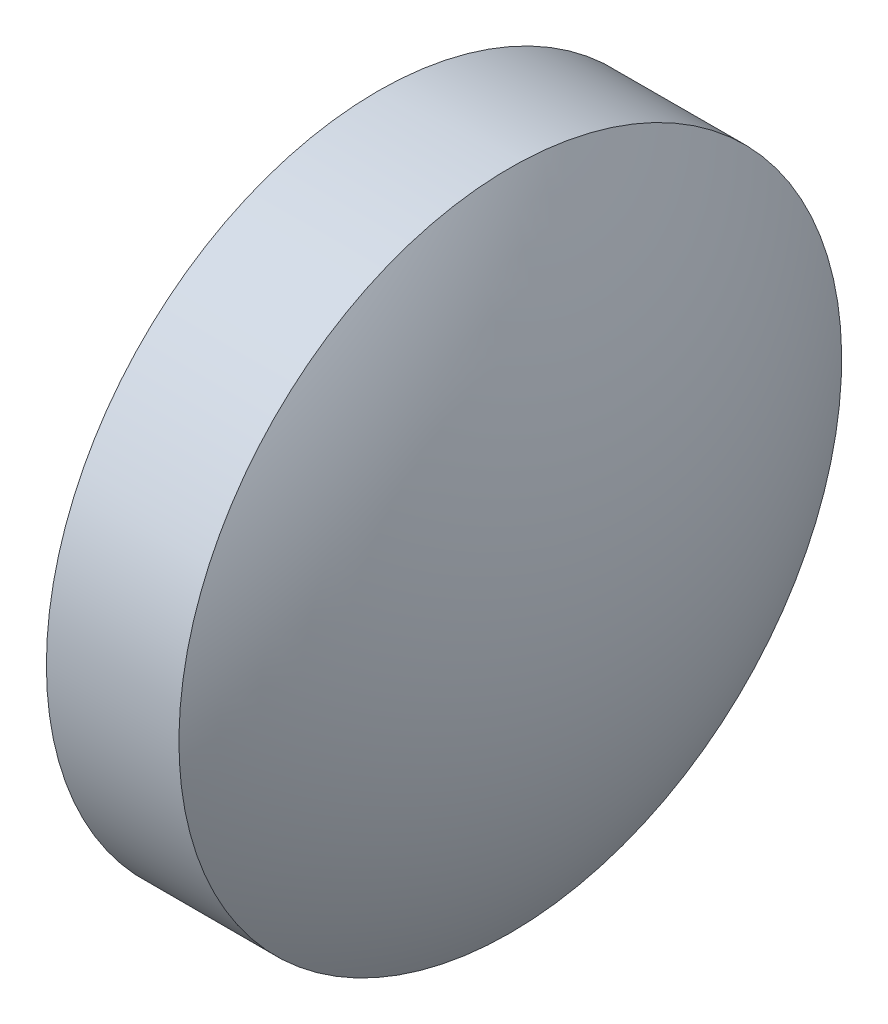
from build123d import *

# Parameters (mm, degrees)
SKETCH_2_ONE_SIDE_W = 2
SKETCH_2_ONE_SIDE_H = 5


with BuildPart() as part:
    # 草图2 one side → 旋转1 (revolve)
    with BuildSketch(Plane.XY, mode=Mode.PRIVATE) as revolve_1_sk:
        with Locations((34.038658966, 21.640201978)):
            Rectangle(SKETCH_2_ONE_SIDE_W, SKETCH_2_ONE_SIDE_H)
        with BuildLine():
            Line((31.603658966, 19.140201978), (33.038658966, 19.140201978))
            Line((33.038658966, 19.140201978), (33.038658966, 24.140201978))
            ThreePointArc((33.038658966, 24.140201978), (31.969506999, 21.741126092), (31.603658966, 19.140201978))
        make_face()
        with BuildLine():
            Line((35.038658966, 19.140201978), (36.473658966, 19.140201978))
            ThreePointArc((36.473658966, 19.140201978), (36.107810934, 21.741126092), (35.038658966, 24.140201978))
            Line((35.038658966, 24.140201978), (35.038658966, 19.140201978))
        make_face()
    revolve(revolve_1_sk.sketch.rotate(Axis((27.045357573, 19.140201978, 0), (1, 0, 0)), 180), axis=Axis((27.045357573, 19.140201978, 0), (1, 0, 0)))  # turned: the seam where the file's is


solid = part.part
